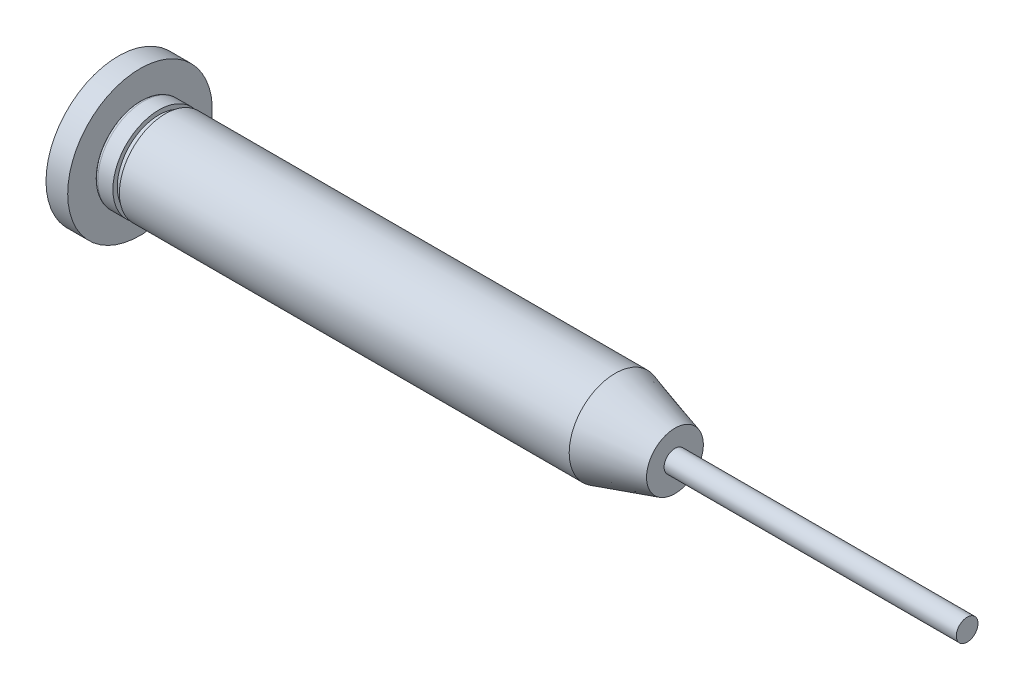
from build123d import *

# Parameters (mm, degrees)
FILLET1_R           = 0.25
SKETCH2_W           = 20.2
SKETCH2_H           = 0.75
SKETCH3_R           = 1.2125
BOSS_EXTRUDE1_DEPTH = 10
SKETCH4_R           = 1.5
CUT_EXTRUDE1_DEPTH  = 15
SKETCH6_R           = 5
BOSS_EXTRUDE2_DEPTH = 1.5


with BuildPart() as part:
    # Sketch1 → Revolve1 (revolve)
    with BuildSketch(Plane.XY):
        Polygon((16.42, 1.5875), (20.555933238, 0.375), (20.555933238, -0.375), (16.42, -1.5875), (-16.42, -1.5875), (-16.42, 1.5875), (-15.12, 1.5875), (-15.12, 1.2875), (-14.67, 1.2875), (-14.67, 1.5875), align=None)
    revolve(axis=Axis((-16.42, -1.5875, 0), (1, 0, 0)))

    # Fillet1
    fillet1_edges = [part.edges().sort_by_distance(p)[0] for p in [
        (-16.42, -4.7625, 0),
    ]]
    fillet(fillet1_edges, radius=FILLET1_R)



with BuildPart() as body_2:
    # Sketch2 → Revolve2 (revolve)
    with BuildSketch(Plane.XY):
        with Locations((30.655933238, -1.2125)):
            Rectangle(SKETCH2_W, SKETCH2_H)
    revolve(axis=Axis((20.555933238, -1.5875, 0), (1, 0, 0)))


with BuildPart() as part_1:
    add(part.part)

    add(body_2.part)  # Boss-Extrude1 merges body 2
    # Sketch3 → Boss-Extrude1 (add)
    with BuildSketch(Plane(origin=(20.555933238, 0, 0), x_dir=(0, 0, -1), z_dir=(1, 0, 0))):
        with Locations((0, -1.5875)):
            Circle(SKETCH3_R)
    extrude(amount=-BOSS_EXTRUDE1_DEPTH)

    # Sketch4 → Cut-Extrude1 (cut)
    with BuildSketch(Plane.ZY.offset(16.42)):
        with Locations((0, -1.5875)):
            Circle(SKETCH4_R)
    extrude(amount=-CUT_EXTRUDE1_DEPTH, mode=Mode.SUBTRACT)

    # Sketch6 → Boss-Extrude2 (add)
    with BuildSketch(Plane.ZY.offset(16.42)):
        with Locations((0, -1.5875)):
            Circle(SKETCH6_R)
    extrude(amount=BOSS_EXTRUDE2_DEPTH)


solid = part_1.part
